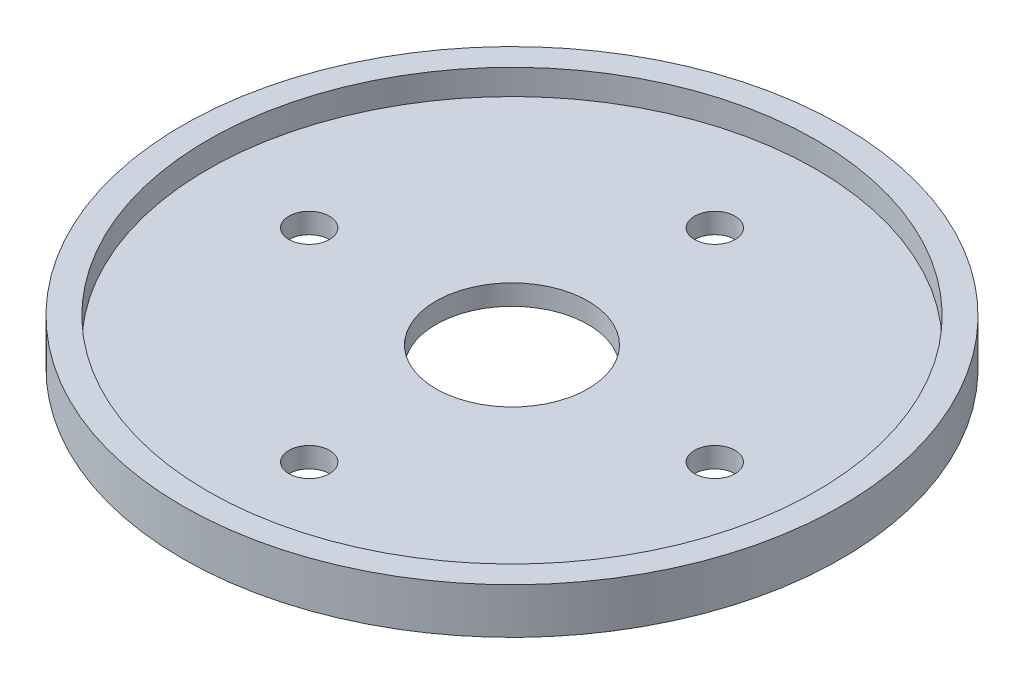
from build123d import *

# Parameters (mm, degrees)
SKETCH1_R        = 41.275
SKETCH1_R_2      = 38.1
SKETCH1_R_3      = 2.54
SKETCH1_R_4      = 9.525
BASE_DEPTH       = 2.54
SKETCH2_R        = 41.275
SKETCH2_R_2      = 38.1
FRONT_WALL_DEPTH = 3.175


with BuildPart() as part:
    # Sketch1 → base (new body)
    with BuildSketch(Plane(origin=(0, 0, 0), x_dir=(1, 0, 0), z_dir=(0, 1, 0))):
        with Locations(Location((0, 0, 0), (0, 0, 270))):
            Circle(SKETCH1_R)
        Circle(SKETCH1_R_2, mode=Mode.SUBTRACT)
        Circle(SKETCH1_R_2)
        with Locations(Location((-25.4, 0, 0), (0, 0, 270))):
            Circle(SKETCH1_R_3, mode=Mode.SUBTRACT)
        with Locations(Location((0, -25.4, 0), (0, 0, 270))):
            Circle(SKETCH1_R_3, mode=Mode.SUBTRACT)
        with Locations(Location((25.4, 0, 0), (0, 0, 270))):
            Circle(SKETCH1_R_3, mode=Mode.SUBTRACT)
        with Locations(Location((0, 25.4, 0), (0, 0, 270))):
            Circle(SKETCH1_R_3, mode=Mode.SUBTRACT)
        with Locations(Location((0, 0, 0), (0, 0, 270))):
            Circle(SKETCH1_R_4, mode=Mode.SUBTRACT)
    extrude(amount=BASE_DEPTH)

    # Sketch2 → front wall (add)
    with BuildSketch(Plane(origin=(0, 2.54, 0), x_dir=(1, 0, 0), z_dir=(0, 1, 0))):
        with Locations(Location((0, 0, 0), (0, 0, 270))):
            Circle(SKETCH2_R)
        with Locations(Location((0, 0, 0), (0, 0, 270))):
            Circle(SKETCH2_R_2, mode=Mode.SUBTRACT)
    extrude(amount=FRONT_WALL_DEPTH)


solid = part.part
